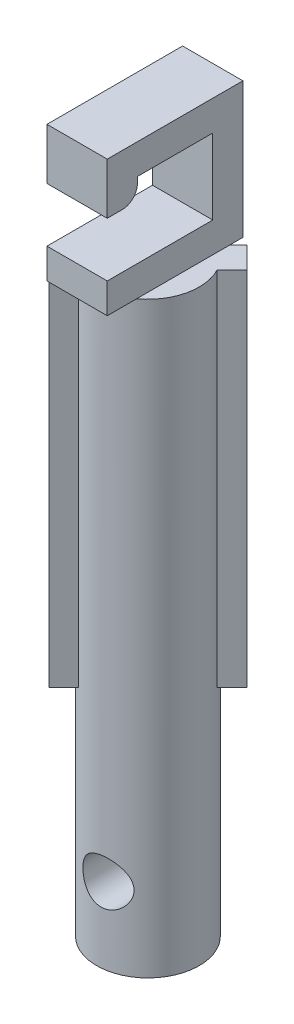
from build123d import *

# Parameters (mm, degrees)
SKETCH1_R             = 1.7
MAIN_SHAFT_DEPTH      = 6
GUIDES_DEPTH          = 12
SKETCH21_W            = 2
SKETCH21_H            = 4.5
HOOK_EXTRUDE_DEPTH    = 4.5
HOOK_CUT_DEPTH        = 3.997440667
HOOK_FILLET_R         = 0.5
SKETCH23_R            = 1.7
TOP_STOPPER_DEPTH     = 2
SKETCH24_R            = 1.7
BOTTOM_SHAFT_DEPTH    = 5.5
F_1_5MM_DOWEL_HOLE2_D = 1.5


with BuildPart() as part:
    # Sketch1 → main shaft (new body, symmetric)
    with BuildSketch(Plane(origin=(0, 0, 0), x_dir=(1, 0, 0), z_dir=(0, 1, 0))):
        Circle(SKETCH1_R)
    extrude(amount=MAIN_SHAFT_DEPTH, both=True)

    # Sketch2 → guides (add)
    with BuildSketch(Plane(origin=(0, 6, 0), x_dir=(1, 0, 0), z_dir=(0, 1, 0))):
        with BuildLine():
            Line((-0.795359139, -1.50246592), (-1.290333886, -1.997440667))
            Line((-1.290333886, -1.997440667), (-1.997440667, -1.290333886))
            Line((-1.997440667, -1.290333886), (-1.50246592, -0.795359139))
            ThreePointArc((-1.50246592, -0.795359139), (-1.202081528, -1.202081528), (-0.795359139, -1.50246592))
        make_face()
        with BuildLine():
            Line((1.290333886, 1.997440667), (0.795359139, 1.50246592))
            ThreePointArc((0.795359139, 1.50246592), (1.202081528, 1.202081528), (1.50246592, 0.795359139))
            Line((1.50246592, 0.795359139), (1.997440667, 1.290333886))
            Line((1.997440667, 1.290333886), (1.290333886, 1.997440667))
        make_face()
    extrude(amount=-GUIDES_DEPTH)

    # Sketch21 → hook extrude (add)
    with BuildSketch(Plane(origin=(0, 6, 0), x_dir=(1, 0, 0), z_dir=(0, 1, 0))):
        with Locations((0, -0.1)):
            Rectangle(SKETCH21_W, SKETCH21_H)
    extrude(amount=HOOK_EXTRUDE_DEPTH)

    # Sketch22 → hook cut (cut, through all)
    with BuildSketch(Plane(origin=(1, 0, 0), x_dir=(0, 0, -1), z_dir=(1, 0, 0))):
        Polygon((-2.35, 7), (1.15, 7), (1.15, 9.5), (-1.35, 9.5), (-1.35, 8.8), (-2.35, 8.8), align=None)
    extrude(amount=-HOOK_CUT_DEPTH, mode=Mode.SUBTRACT)

    # hook fillet
    hook_fillet_edges = [part.edges().sort_by_distance(p)[0] for p in [
        (0, 8.8, 1.35),
    ]]
    fillet(hook_fillet_edges, radius=HOOK_FILLET_R)

    # Sketch23 → top stopper (add)
    with BuildSketch(Plane.XZ.offset(6)):
        Circle(SKETCH23_R)
    extrude(amount=TOP_STOPPER_DEPTH)

    # Sketch24 → bottom shaft (add)
    with BuildSketch(Plane.XZ.offset(8)):
        Circle(SKETCH24_R)
    extrude(amount=BOTTOM_SHAFT_DEPTH)

    # Ø1.5mm Dowel Hole2 (through all)
    with Locations(Plane.XY.offset(2.35)):
        with Locations((0.2, -11)):
            Hole(F_1_5MM_DOWEL_HOLE2_D / 2)


solid = part.part
